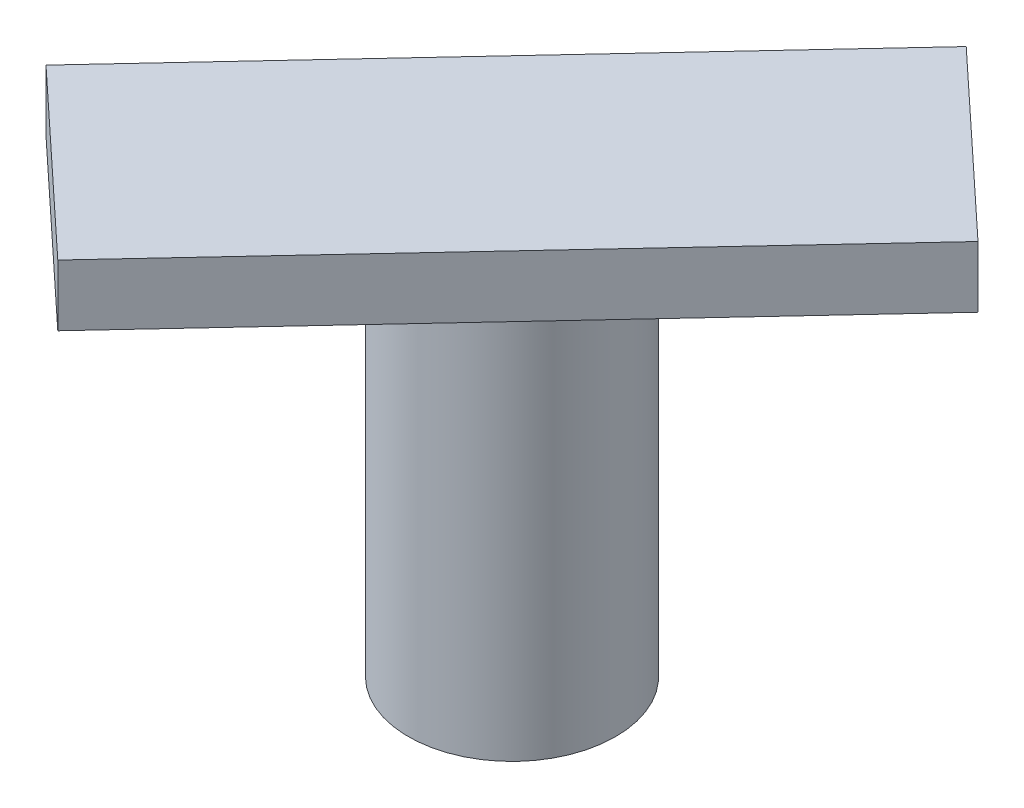
from build123d import *

# Parameters (mm, degrees)
SKETCH1_R             = 16.916621232
BOSS_EXTRUDE1_DEPTH   = 64
SKETCH2_W             = 106.262974488
SKETCH2_H             = 38.987679284
BOSS_EXTRUDE2_DEPTH   = 10
BODY_MOVE_COPY1_ANGLE = 47


with BuildPart() as part:
    # Sketch1 → Boss-Extrude1 (new body)
    with BuildSketch(Plane(origin=(0, 0, 0), x_dir=(1, 0, 0), z_dir=(0, 1, 0))):
        with Locations((22.72979363, -8.239550191)):
            Circle(SKETCH1_R)
    extrude(amount=BOSS_EXTRUDE1_DEPTH)

    # Sketch2 → Boss-Extrude2 (add)
    with BuildSketch(Plane(origin=(0, 64, 0), x_dir=(1, 0, 0), z_dir=(0, 1, 0))):
        with Locations((22.72979363, -8.239550191)):
            Rectangle(SKETCH2_W, SKETCH2_H)
    extrude(amount=BOSS_EXTRUDE2_DEPTH)


with BuildPart() as part_1:
    # Body-Move/Copy1: moved
    add(part.part.rotate(Axis((22.72979363, 0, 8.239550191), (0, 1, 0)), BODY_MOVE_COPY1_ANGLE))


solid = part_1.part
